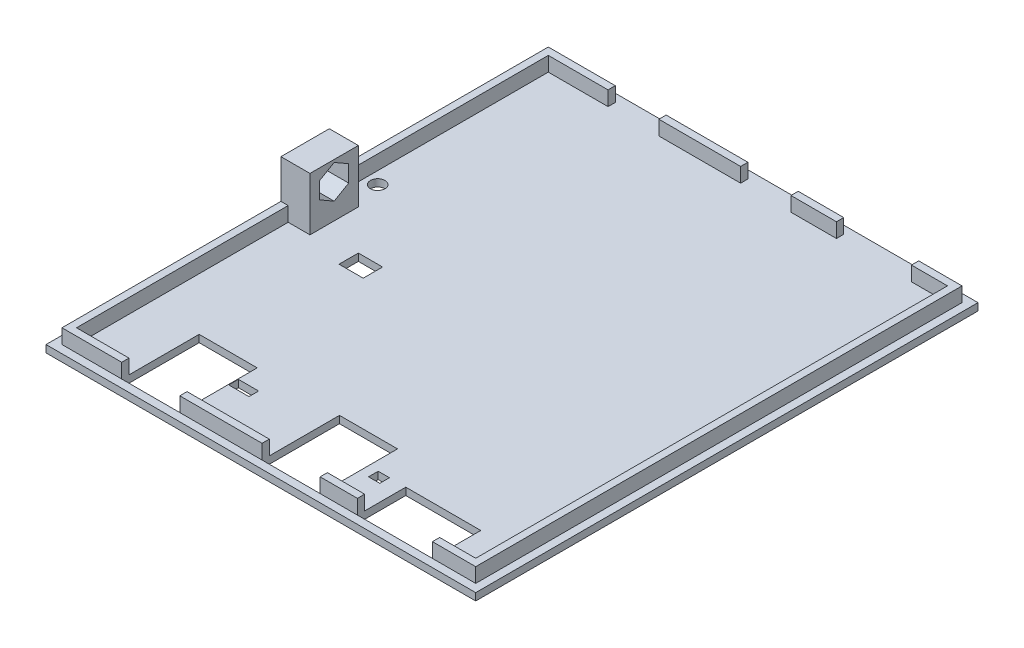
from build123d import *

# Parameters (mm, degrees)
SKETCH_1_W          = 88.8
SKETCH_1_H          = 103.8
EXTRUDE_1_DEPTH     = 1.5
SKETCH_2_W          = 85.5
SKETCH_2_H          = 100.5
SKETCH_2_W_2        = 82.5
SKETCH_2_H_2        = 97.5
EXTRUDE_2_DEPTH     = 3
EXTRUDE_3_DEPTH     = 6
SKETCH_6_W          = 10.5
SKETCH_6_H          = 6
SKETCH_6_W_2        = 15.5
SKETCH_6_W_3        = 10.4
CUT_EXTRUDE_2_DEPTH = 1.5
SKETCH_7_R          = 1.5
SKETCH_7_W          = 15.5
SKETCH_7_H          = 10
SKETCH_7_W_2        = 12
SKETCH_7_H_2        = 16
SKETCH_7_W_3        = 2.325623679
SKETCH_7_H_3        = 2
SKETCH_7_W_4        = 4.188972838
SKETCH_7_W_5        = 5
SKETCH_7_H_4        = 4
CUT_EXTRUDE_5_DEPTH = 10


with BuildPart() as part:
    # 草图1 → 凸台-拉伸1 (new body)
    with BuildSketch(Plane(origin=(0, 0, 0), x_dir=(1, 0, 0), z_dir=(0, 1, 0))):
        Rectangle(SKETCH_1_W, SKETCH_1_H)
    extrude(amount=EXTRUDE_1_DEPTH)

    # 草图2 → 凸台-拉伸2 (add)
    with BuildSketch(Plane(origin=(0, 1.5, 0), x_dir=(1, 0, 0), z_dir=(0, 1, 0))):
        Rectangle(SKETCH_2_W, SKETCH_2_H)
        Rectangle(SKETCH_2_W_2, SKETCH_2_H_2, mode=Mode.SUBTRACT)
    extrude(amount=EXTRUDE_2_DEPTH)

    # 草图3 → 凸台-拉伸3 (add)
    with BuildSketch(Plane.ZY.offset(42.75)):
        Polygon((5, 12.5), (-5, 12.5), (-5, 4.5), (-5, 1.5), (5, 1.5), (5, 4.5), align=None)
        Polygon((0, 11.964101615), (-3, 10.232050808), (-3, 6.767949192), (0, 5.035898385), (3, 6.767949192), (3, 10.232050808), align=None, mode=Mode.SUBTRACT)
    extrude(amount=-EXTRUDE_3_DEPTH)

    # 草图6 → 切除-拉伸2 (cut)
    with BuildSketch(Plane(origin=(0, 0, -50.25), x_dir=(-1, 0, 0), z_dir=(0, 0, -1))):
        with Locations((23.65, 4.5)):
            Rectangle(SKETCH_6_W, SKETCH_6_H)
        with Locations((-26.05, 4.5)):
            Rectangle(SKETCH_6_W_2, SKETCH_6_H)
        with Locations((-3.7, 4.5)):
            Rectangle(SKETCH_6_W_3, SKETCH_6_H)
    extrude(amount=-CUT_EXTRUDE_2_DEPTH, mode=Mode.SUBTRACT)

    # 草图7 → 切除-拉伸5 (cut)
    with BuildSketch(Plane(origin=(0, 0, 0), x_dir=(1, 0, 0), z_dir=(0, 1, 0))):
        with Locations((-38.75, 11)):
            Circle(SKETCH_7_R)
        with Locations((26.05, -45.25)):
            Rectangle(SKETCH_7_W, SKETCH_7_H)
        with Locations((4.6, -42.25)):
            Rectangle(SKETCH_7_W_2, SKETCH_7_H_2)
        with Locations((-24.4, -42.25)):
            Rectangle(SKETCH_7_W_2, SKETCH_7_H_2)
        with Locations((13.76281184, -41.25)):
            Rectangle(SKETCH_7_W_3, SKETCH_7_H_3)
        with Locations((-16.205513581, -39.25)):
            Rectangle(SKETCH_7_W_4, SKETCH_7_H_3)
        with Locations((-26, -5.25)):
            Rectangle(SKETCH_7_W_5, SKETCH_7_H_4)
    extrude(amount=CUT_EXTRUDE_5_DEPTH, mode=Mode.SUBTRACT)


solid = part.part
